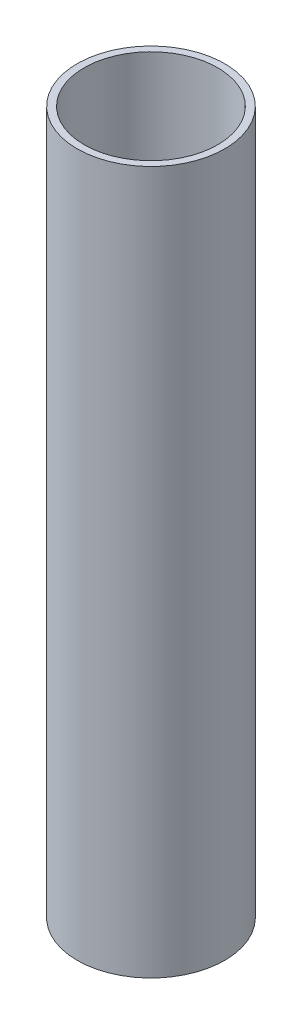
from build123d import *

# Parameters (mm, degrees)
SKETCH1_R           = 21
SKETCH1_R_2         = 19
BOSS_EXTRUDE1_DEPTH = 200


with BuildPart() as part:
    # Sketch1 → Boss-Extrude1 (new body)
    with BuildSketch(Plane(origin=(0, 0, 0), x_dir=(1, 0, 0), z_dir=(0, 1, 0))):
        Circle(SKETCH1_R)
        Circle(SKETCH1_R_2, mode=Mode.SUBTRACT)
    extrude(amount=BOSS_EXTRUDE1_DEPTH)


solid = part.part
